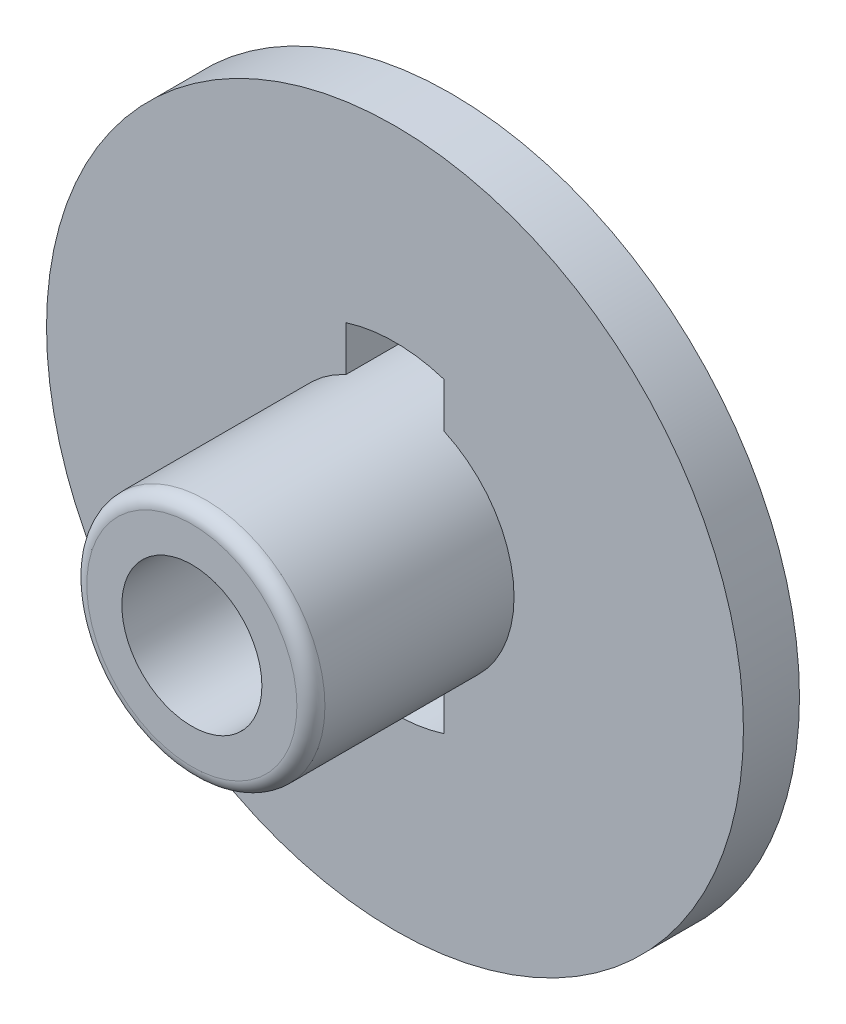
from build123d import *

# Parameters (mm, degrees)
SKETCH_1_R          = 4.975
EXTRUDE_1_DEPTH     = 0.8
SKETCH_1_6_R        = 1.7
EXTRUDE_2_DEPTH     = 3.7
SKETCH_1_4_R        = 1.15
CUT_EXTRUDE_1_DEPTH = 0.5
SKETCH_1_7_R        = 1
CUT_EXTRUDE_2_DEPTH = 4.7
FILLET_1_R          = 0.2


with BuildPart() as part:
    # Sketch 1 → Extrude 1 (new body)
    with BuildSketch(Plane.XY):
        Circle(SKETCH_1_R)
    extrude(amount=EXTRUDE_1_DEPTH)

    # Sketch 1_6 → Extrude 2 (add)
    with BuildSketch(Plane.XY):
        Circle(SKETCH_1_6_R)
    extrude(amount=EXTRUDE_2_DEPTH)

    # Sketch 1_4 → Cut-Extrude 1 (cut)
    with BuildSketch(Plane.XY):
        Circle(SKETCH_1_4_R)
    extrude(amount=CUT_EXTRUDE_1_DEPTH, mode=Mode.SUBTRACT)

    # Sketch 1_7 → Cut-Extrude 2 (cut, through all)
    with BuildSketch(Plane.XY):
        with BuildLine():
            Line((-0.7, -1.549193338), (-0.7, -2.19089023))
            ThreePointArc((-0.7, -2.19089023), (0, -2.3), (0.7, -2.19089023))
            Line((0.7, -2.19089023), (0.7, -1.549193338))
            ThreePointArc((0.7, -1.549193338), (0, -1.7), (-0.7, -1.549193338))
        make_face()
        with BuildLine():
            ThreePointArc((0.7, 2.19089023), (0, 2.3), (-0.7, 2.19089023))
            Line((-0.7, 2.19089023), (-0.7, 1.549193338))
            ThreePointArc((-0.7, 1.549193338), (0, 1.7), (0.7, 1.549193338))
            Line((0.7, 1.549193338), (0.7, 2.19089023))
        make_face()
        with BuildLine():
            Line((-0.7, -1.549193338), (-0.7, -2.19089023))
            ThreePointArc((-0.7, -2.19089023), (0, -2.3), (0.7, -2.19089023))
            Line((0.7, -2.19089023), (0.7, -1.549193338))
            ThreePointArc((0.7, -1.549193338), (0, -1.7), (-0.7, -1.549193338))
        make_face()
        with BuildLine():
            ThreePointArc((0.7, 2.19089023), (0, 2.3), (-0.7, 2.19089023))
            Line((-0.7, 2.19089023), (-0.7, 1.549193338))
            ThreePointArc((-0.7, 1.549193338), (0, 1.7), (0.7, 1.549193338))
            Line((0.7, 1.549193338), (0.7, 2.19089023))
        make_face()
        Circle(SKETCH_1_7_R)
    extrude(amount=CUT_EXTRUDE_2_DEPTH, mode=Mode.SUBTRACT)

    # Fillet 1
    fillet_1_edges = [part.edges().sort_by_distance(p)[0] for p in [
        (1.428285686, 0.921954446, 3.7),
    ]]
    fillet(fillet_1_edges, radius=FILLET_1_R)


solid = part.part
